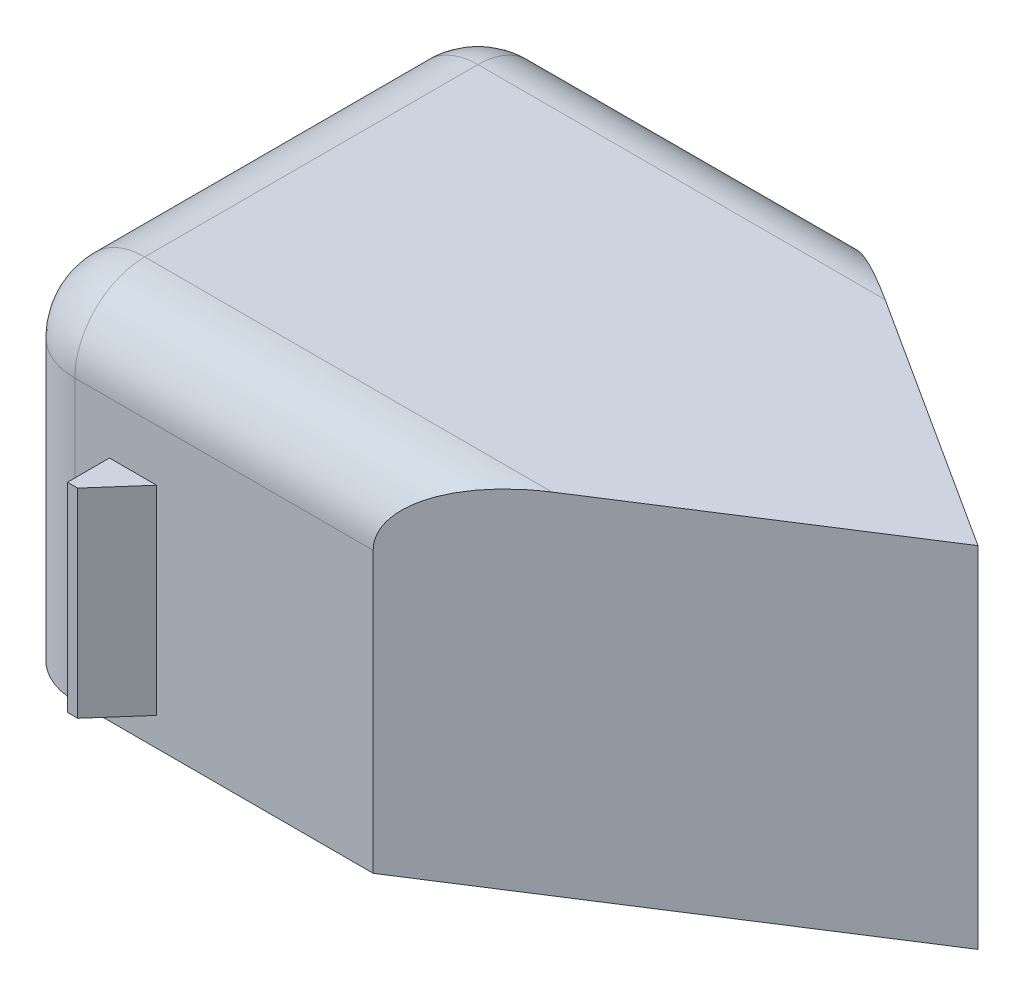
from build123d import *

# Parameters (mm, degrees)
BOSS_EXTRUDE1_DEPTH = 50
FILLET1_R           = 10
SKETCH2_W           = 6.733148768
SKETCH2_H           = 28.503663117
BOSS_EXTRUDE2_DEPTH = 6
CUT_EXTRUDE1_DEPTH  = 29


with BuildPart() as part:
    # Sketch1 → Boss-Extrude1 (new body)
    with BuildSketch(Plane(origin=(0, 0, 0), x_dir=(1, 0, 0), z_dir=(0, 1, 0))):
        with BuildLine():
            Line((0, -33.816412485), (52.662713514, 0))
            Line((52.662713514, 0), (0, 33.816412485))
            Line((0, 33.816412485), (-42.662713514, 33.816412485))
            ThreePointArc((-42.662713514, 33.816412485), (-49.733781326, 30.887480297), (-52.662713514, 23.816412485))
            Line((-52.662713514, 23.816412485), (-52.662713514, -23.816412485))
            ThreePointArc((-52.662713514, -23.816412485), (-49.733781326, -30.887480297), (-42.662713514, -33.816412485))
            Line((-42.662713514, -33.816412485), (0, -33.816412485))
        make_face()
    extrude(amount=BOSS_EXTRUDE1_DEPTH)

    # Fillet1
    fillet1_edges = [part.edges().sort_by_distance(p)[0] for p in [
        (-49.733781326, 50, -30.887480297),
        (-52.662713514, 50, 0),
        (-49.733781326, 50, 30.887480297),
        (-21.331356757, 50, 33.816412485),
        (-21.331356757, 50, -33.816412485),
    ]]
    fillet(fillet1_edges, radius=FILLET1_R)

    # Sketch2 → Boss-Extrude2 (add)
    with BuildSketch(Plane.XY.offset(33.816412485)):
        with Locations((-34.339058715, 18.322960806)):
            Rectangle(SKETCH2_W, SKETCH2_H)
    extrude(amount=BOSS_EXTRUDE2_DEPTH)

    # Sketch3 → Cut-Extrude1 (cut)
    with BuildSketch(Plane(origin=(0, 4.071129247, 0), x_dir=(-1, 0, 0), z_dir=(0, -1, 0))):
        Polygon((30.972484331, -33.816412485), (36.246784199, -39.816412485), (30.972484331, -39.816412485), align=None)
    extrude(amount=-CUT_EXTRUDE1_DEPTH, mode=Mode.SUBTRACT)


solid = part.part
